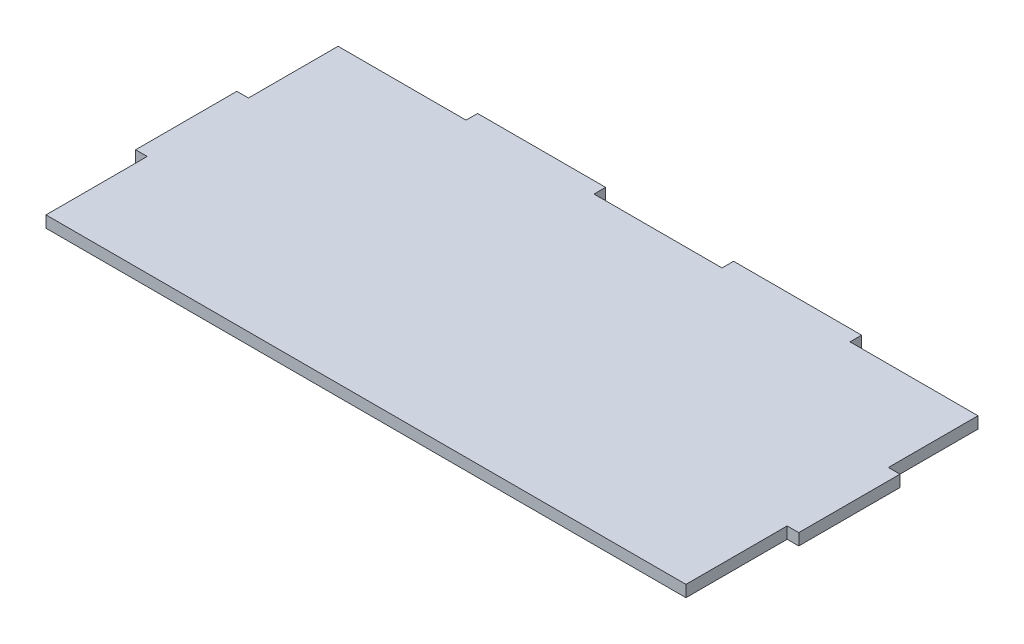
from build123d import *

# Parameters (mm, degrees)
BOSS_EXTRUDE1_DEPTH = 2.7


with BuildPart() as part:
    # Sketch1 → Boss-Extrude1 (new body)
    with BuildSketch(Plane(origin=(0, 0, 0), x_dir=(1, 0, 0), z_dir=(0, 1, 0))):
        Polygon((144, 18.566666667), (144, -5), (115.82, -5), (84.94, -5), (74.5, -5), (64.5, -5), (54.06, -5), (23.18, -5), (-5, -5), (-5, 18.566666667), (-7.7, 18.566666667), (-7.7, 42.133333333), (-5, 42.133333333), (-5, 63), (24.8, 63), (24.8, 65.7), (54.6, 65.7), (54.6, 63), (64.5, 63), (74.5, 63), (84.4, 63), (84.4, 65.7), (114.2, 65.7), (114.2, 63), (144, 63), (144, 42.133333333), (146.7, 42.133333333), (146.7, 18.566666667), align=None)
    extrude(amount=BOSS_EXTRUDE1_DEPTH)


solid = part.part
